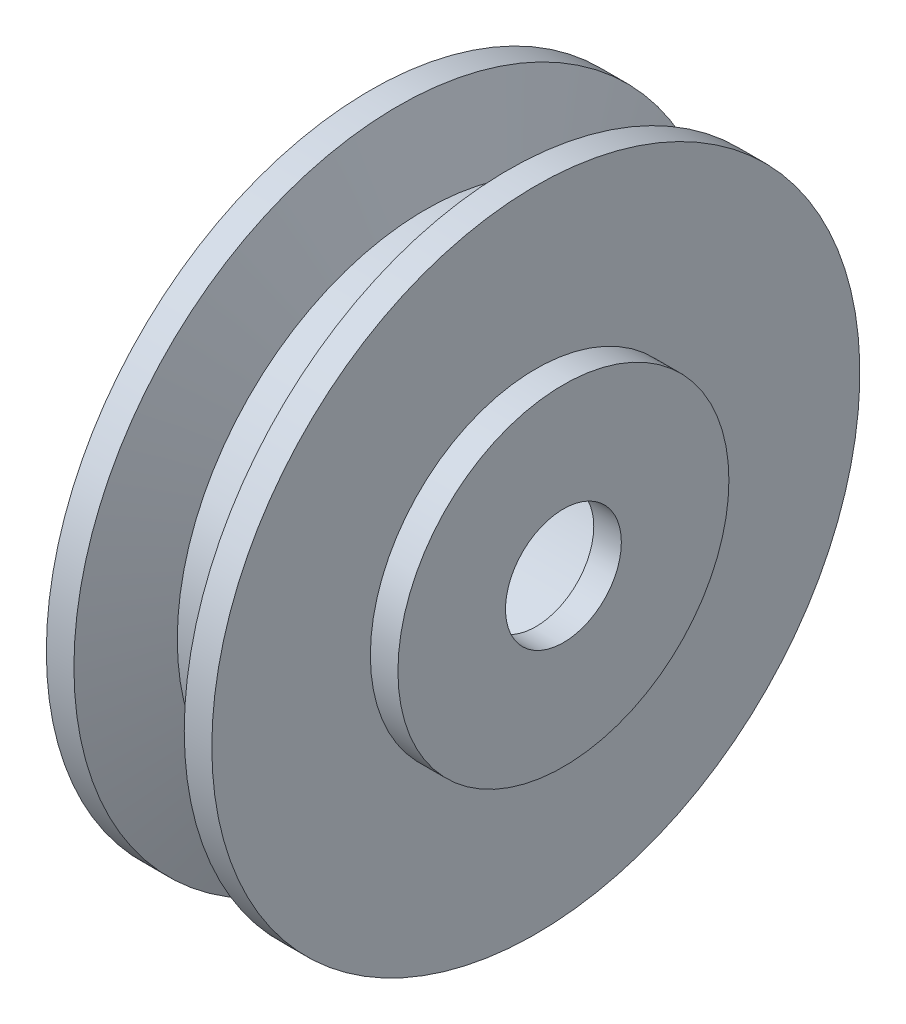
from build123d import *

# Parameters (mm, degrees)
SKETCH3_R           = 5
CUT_EXTRUDE1_DEPTH  = 87
SKETCH5_R           = 6
SKETCH5_R_2         = 2.1
BOSS_EXTRUDE2_DEPTH = 1
SKETCH7_R           = 6
SKETCH7_R_2         = 2.1
BOSS_EXTRUDE3_DEPTH = 1


with BuildPart() as part:
    # Sketch1 → Revolve1 (revolve)
    with BuildSketch(Plane.XY):
        Polygon((0, 0), (0, 9), (1, 9), (2, 11.747477419), (3, 11.747477419), (3, 0), align=None)
    revolve1 = revolve(axis=Axis((0, 0, 0), (1, 0, 0)))

    # Mirror1: Revolve1 across plane
    add(revolve1.mirror(Plane(origin=(0, 0, 0), x_dir=(0, 0, 1), z_dir=(1, 0, 0))))

    # Sketch3 → Cut-Extrude1 (cut)
    with BuildSketch(Plane(origin=(3, 0, 0), x_dir=(0, 0, -1), z_dir=(1, 0, 0))):
        Circle(SKETCH3_R)
    extrude(amount=-CUT_EXTRUDE1_DEPTH, mode=Mode.SUBTRACT)

    # Sketch5 → Boss-Extrude2 (add)
    with BuildSketch(Plane(origin=(3, 0, 0), x_dir=(0, 0, -1), z_dir=(1, 0, 0))):
        Circle(SKETCH5_R)
        Circle(SKETCH5_R_2, mode=Mode.SUBTRACT)
    extrude(amount=BOSS_EXTRUDE2_DEPTH)


with BuildPart() as body_2:
    # Sketch7 → Boss-Extrude3 (new body)
    with BuildSketch(Plane.ZY.offset(3)):
        Circle(SKETCH7_R)
        Circle(SKETCH7_R_2, mode=Mode.SUBTRACT)
    extrude(amount=BOSS_EXTRUDE3_DEPTH)


solid = Compound([part.part, body_2.part])
